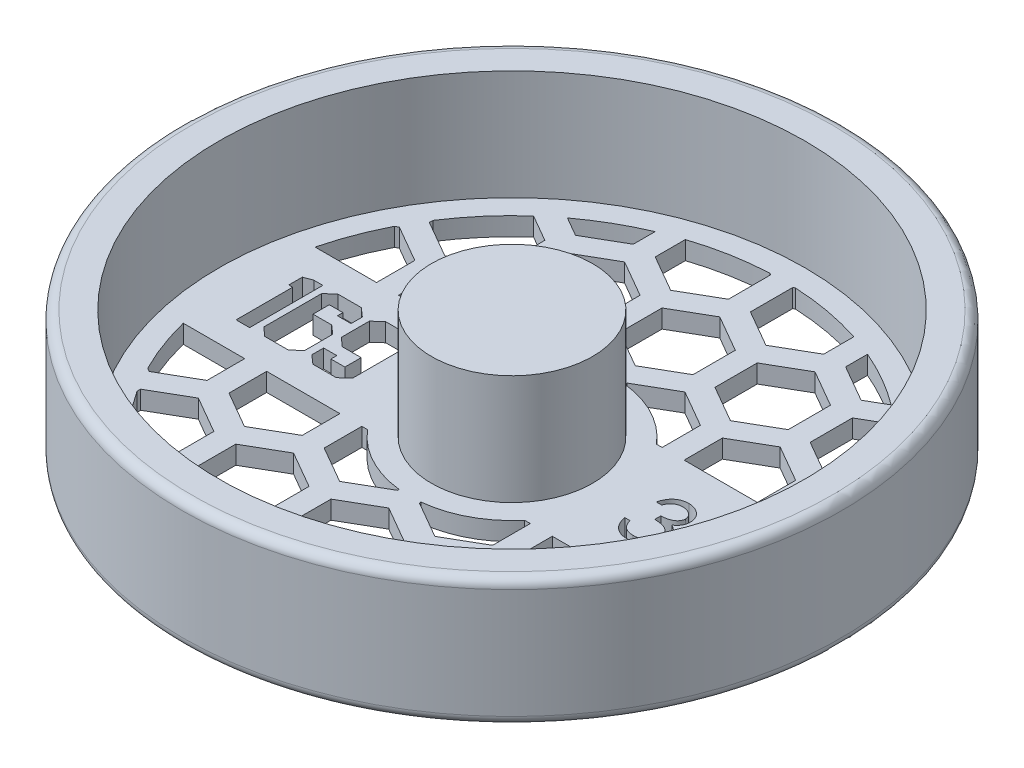
from build123d import *

# Parameters (mm, degrees)
CUT_EXTRUDE2_DEPTH      = 20.05
CUT_EXTRUDE2_DEPTH_BACK = 4.175
CUT_EXTRUDE4_DEPTH      = 20.05
CUT_EXTRUDE4_DEPTH_BACK = 4.1750001


with BuildPart() as part:
    # Sketch1 → Revolve1 (revolve)
    with BuildSketch(Plane.XY):
        with BuildLine():
            Line((0, 0), (0, 22.225))
            Line((0, 22.225), (13.97, 22.225))
            Line((13.97, 22.225), (13.97, 3.175))
            Line((13.97, 3.175), (50.8, 3.175))
            Line((50.8, 3.175), (50.8, 22.225))
            Line((50.8, 22.225), (55.5625, 22.225))
            ThreePointArc((55.5625, 22.225), (56.685032015, 21.760032015), (57.15, 20.6375))
            Line((57.15, 20.6375), (57.15, 1.5875))
            ThreePointArc((57.15, 1.5875), (56.685032015, 0.464967985), (55.5625, 0))
            Line((55.5625, 0), (0, 0))
        make_face()
    revolve(axis=Axis((0, 0, 0), (0, 1, 0)))

    # Sketch3 → Cut-Extrude2 (cut, two sides)
    with BuildSketch(Plane(origin=(0, 3.175, 0), x_dir=(1, 0, 0), z_dir=(0, 1, 0))) as cut_extrude2_sk:
        Polygon((-22.636037344, -5.022991324), (-24.137904564, -6.35), (-28.181208978, -6.35), (-29.68547152, -5.022991324), (-29.68547152, -2.979781215), (-27.397938514, -2.979781215), (-27.397938514, -4.004979253), (-24.978662769, -4.004979253), (-24.978662769, -1.176103357), (-28.253068653, -1.176103357), (-29.750145228, 0.150905319), (-29.750145228, 5.015805356), (-28.253068653, 6.35), (-24.154671822, 6.35), (-22.636037344, 5.008619389), align=None)
        Polygon((-30.945411166, -5.022991324), (-32.449673708, -6.35), (-36.524117314, -6.35), (-38.028379857, -5.022991324), (-38.028379857, 5.015805356), (-36.540884572, 6.35), (-32.473626933, 6.35), (-30.969364391, 5.015805356), (-30.969364391, 3.05164089), (-33.321571105, 3.05164089), (-33.321571105, 4.004979253), (-35.68335911, 4.004979253), (-35.68335911, 1.176103357), (-32.449673708, 1.176103357), (-30.945411166, -0.141324029), align=None)
        Polygon((-39.151786118, -6.35), (-41.496806865, -6.35), (-41.496806865, 3.463636364), (-42.167497171, 3.463636364), (-42.167497171, 5.808657111), (-40.720722369, 6.35), (-39.151786118, 6.35), align=None)
        with BuildLine():
            Line((23.201923077, 2.735384615), (22.290128205, 2.735384615))
            add(Edge.make_bspline(
                [(22.290128205, 2.735384615), (22.314830215, 2.837659483), (22.363120624, 3.037598484), (22.463842723, 3.323260704), (22.573568561, 3.593584984), (22.705326647, 3.843509586), (22.849043488, 4.078057258), (23.013701446, 4.291908202), (23.19170384, 4.490501268), (23.388589979, 4.666743123), (23.595066322, 4.826335617), (23.814042247, 4.962407212), (24.041112133, 5.079462467), (24.277849227, 5.175896054), (24.524958343, 5.248541575), (24.780205478, 5.301248187), (25.044259524, 5.335476107), (25.223503958, 5.338816608), (25.314519231, 5.340512821)],
                knots=[0, 0, 0, 0, 0.000315438, 0.000616656, 0.000907698, 0.001189895, 0.001463234, 0.001731895, 0.001998452, 0.002262133, 0.002523472, 0.002780414, 0.003034373, 0.003289106, 0.00354604, 0.003805892, 0.004070452, 0.004343366, 0.004343366, 0.004343366, 0.004343366], degree=3))
            add(Edge.make_bspline(
                [(25.314519231, 5.340512821), (25.447129705, 5.336509112), (25.709458034, 5.328589028), (26.094850193, 5.256265978), (26.466493759, 5.141820451), (26.820320833, 4.983691003), (27.148977769, 4.788655831), (27.441400528, 4.556529623), (27.693625462, 4.29179108), (27.905227427, 3.999378836), (28.070907996, 3.686870271), (28.193078726, 3.365233244), (28.267454805, 3.035230721), (28.277093907, 2.812415305), (28.281923077, 2.700785256)],
                knots=[0, 0, 0, 0, 0.000397506, 0.000786341, 0.001171951, 0.001561898, 0.001946195, 0.002315542, 0.002678309, 0.003039829, 0.003394922, 0.003736275, 0.004069616, 0.004404291, 0.004404291, 0.004404291, 0.004404291], degree=3))
            add(Edge.make_bspline(
                [(28.281923077, 2.700785256), (28.278545338, 2.593359818), (28.271935628, 2.383144906), (28.215812643, 2.076250503), (28.12136452, 1.787005171), (27.990533437, 1.514191284), (27.821176252, 1.259538606), (27.616023509, 1.022474191), (27.37362721, 0.801946578), (27.189937493, 0.675615765), (27.09536859, 0.610576923)],
                knots=[0, 0, 0, 0, 0.000322092, 0.000630284, 0.00093214, 0.001232539, 0.001535102, 0.001846808, 0.002171002, 0.002515015, 0.002515015, 0.002515015, 0.002515015], degree=3))
            add(Edge.make_bspline(
                [(27.09536859, 0.610576923), (27.203447054, 0.558388859), (27.417581752, 0.454989211), (27.709465575, 0.252207926), (27.974432208, 0.018074072), (28.122198432, -0.164639457), (28.196442308, -0.256442308)],
                knots=[0, 0, 0, 0, 0.000359556, 0.000712384, 0.001062596, 0.001416244, 0.001416244, 0.001416244, 0.001416244], degree=3))
            add(Edge.make_bspline(
                [(28.196442308, -0.256442308), (28.245330319, -0.323375667), (28.342305765, -0.456146304), (28.462006629, -0.669612044), (28.570599944, -0.885443795), (28.655218866, -1.109426528), (28.720747577, -1.338964191), (28.767588173, -1.574450918), (28.796686822, -1.816079006), (28.800854025, -1.979546091), (28.802948718, -2.061714744)],
                knots=[0, 0, 0, 0, 0.000248435, 0.000492801, 0.000733099, 0.000972742, 0.001209812, 0.001448502, 0.001692367, 0.001938844, 0.001938844, 0.001938844, 0.001938844], degree=3))
            add(Edge.make_bspline(
                [(28.802948718, -2.061714744), (28.797739502, -2.203982963), (28.787345583, -2.487849885), (28.694442328, -2.907239362), (28.550422178, -3.31719682), (28.345895758, -3.709299782), (28.096634646, -4.076163974), (27.800086528, -4.404408345), (27.45962084, -4.686562008), (27.079910728, -4.922303699), (26.668526149, -5.110751153), (26.228523859, -5.241546473), (25.766243702, -5.326733718), (25.449230519, -5.335868628), (25.288060897, -5.340512821)],
                knots=[0, 0, 0, 0, 0.000426322, 0.000850637, 0.001282577, 0.001726786, 0.002173324, 0.002609918, 0.00304927, 0.003495414, 0.003947167, 0.00440236, 0.004869477, 0.005352558, 0.005352558, 0.005352558, 0.005352558], degree=3))
            add(Edge.make_bspline(
                [(25.288060897, -5.340512821), (25.179438014, -5.337992521), (24.965704402, -5.333033413), (24.651488989, -5.299132102), (24.351560856, -5.237214144), (24.065514481, -5.153892549), (23.793095747, -5.048252521), (23.535135944, -4.916698815), (23.290048025, -4.76194314), (23.060144784, -4.582158782), (22.845453627, -4.38104495), (22.651680005, -4.155031367), (22.475593292, -3.908296046), (22.321908375, -3.637973117), (22.183625107, -3.347556028), (22.069888387, -3.033326101), (21.969781707, -2.698092483), (21.923238851, -2.4644771), (21.899358974, -2.344615385)],
                knots=[0, 0, 0, 0, 0.00032587, 0.000641203, 0.000946553, 0.001243456, 0.001534099, 0.001821726, 0.002110819, 0.002402315, 0.002696028, 0.002991841, 0.003293972, 0.003603973, 0.003923534, 0.004257744, 0.004605529, 0.004971988, 0.004971988, 0.004971988, 0.004971988], degree=3))
            Line((21.899358974, -2.344615385), (22.811153846, -2.344615385))
            add(Edge.make_bspline(
                [(22.811153846, -2.344615385), (22.834908772, -2.42284452), (22.881114167, -2.575006984), (22.959765043, -2.793999414), (23.049371227, -2.994755363), (23.14549806, -3.178747512), (23.246454921, -3.347787857), (23.359419389, -3.49740654), (23.476024679, -3.634175241), (23.563921316, -3.711230457), (23.606939103, -3.748942308)],
                knots=[0, 0, 0, 0, 0.000245255, 0.000477042, 0.000697536, 0.000904182, 0.001099652, 0.001287304, 0.001466129, 0.001637538, 0.001637538, 0.001637538, 0.001637538], degree=3))
            add(Edge.make_bspline(
                [(23.606939103, -3.748942308), (23.663825165, -3.792799643), (23.777421695, -3.880378935), (23.96253176, -3.992143662), (24.157211543, -4.088985953), (24.365679283, -4.162961481), (24.583436446, -4.225598348), (24.81400274, -4.266588198), (25.05534401, -4.294711575), (25.220132718, -4.297193319), (25.304342949, -4.298461538)],
                knots=[0, 0, 0, 0, 0.000215334, 0.000430002, 0.000647547, 0.000866467, 0.001092637, 0.001326558, 0.001568172, 0.001820675, 0.001820675, 0.001820675, 0.001820675], degree=3))
            add(Edge.make_bspline(
                [(25.304342949, -4.298461538), (25.399421688, -4.296673654), (25.585339954, -4.293177599), (25.85662606, -4.261026404), (26.114711679, -4.214202118), (26.356731373, -4.141883288), (26.58585536, -4.052530874), (26.798871805, -3.940340074), (26.998577074, -3.808710825), (27.182413291, -3.65910001), (27.347717964, -3.49531647), (27.493265808, -3.324009955), (27.616999111, -3.145902747), (27.716809727, -2.96000923), (27.795623895, -2.767099194), (27.849277986, -2.566631278), (27.886584099, -2.360246071), (27.889622264, -2.219953979), (27.891153846, -2.149230769)],
                knots=[0, 0, 0, 0, 0.000285118, 0.000557523, 0.000818576, 0.001071029, 0.001314045, 0.001555289, 0.001791808, 0.002030524, 0.002265109, 0.002488959, 0.002704052, 0.002914404, 0.003120759, 0.003327646, 0.003536098, 0.003748009, 0.003748009, 0.003748009, 0.003748009], degree=3))
            add(Edge.make_bspline(
                [(27.891153846, -2.149230769), (27.886711599, -2.054564711), (27.87784921, -1.86570364), (27.810187734, -1.587849196), (27.698895488, -1.320137805), (27.543091855, -1.067136997), (27.353431568, -0.832656094), (27.131755153, -0.623442877), (26.876221782, -0.450809698), (26.641032676, -0.331535198), (26.432708679, -0.250147574), (26.254428591, -0.19593682), (26.054837994, -0.150032037), (25.836350536, -0.107324414), (25.597319942, -0.07097673), (25.338006442, -0.04066563), (25.058357488, -0.01641214), (24.864762561, -0.005581303), (24.765, 0)],
                knots=[0, 0, 0, 0, 0.000283785, 0.000566158, 0.00085266, 0.001150399, 0.001454273, 0.001755223, 0.002061196, 0.002376128, 0.002544317, 0.00273166, 0.002934554, 0.003158479, 0.003399405, 0.003659679, 0.003941605, 0.004241348, 0.004241348, 0.004241348, 0.004241348], degree=3))
            Line((24.765, 0), (24.765, 1.042051282))
            add(Edge.make_bspline(
                [(24.765, 1.042051282), (24.890697098, 1.044184312), (25.136906836, 1.048362395), (25.496554303, 1.098895362), (25.840465404, 1.168797985), (26.16101846, 1.275870429), (26.453187297, 1.400229691), (26.706663627, 1.544943533), (26.917896261, 1.705804634), (27.085858685, 1.885295865), (27.212217818, 2.077798975), (27.304606464, 2.278434758), (27.359181125, 2.488961746), (27.36646633, 2.632637697), (27.370128205, 2.704855769)],
                knots=[0, 0, 0, 0, 0.000376792, 0.000738043, 0.001087728, 0.0014282, 0.001749964, 0.002039013, 0.002301593, 0.002543523, 0.002772704, 0.002989485, 0.00320372, 0.003420233, 0.003420233, 0.003420233, 0.003420233], degree=3))
            add(Edge.make_bspline(
                [(27.370128205, 2.704855769), (27.368925229, 2.757913452), (27.366531966, 2.863469196), (27.336350154, 3.017683681), (27.290995795, 3.16718357), (27.228643209, 3.311333099), (27.14518549, 3.449132523), (27.045309826, 3.58175666), (26.926385283, 3.708448316), (26.790109357, 3.826537472), (26.643771089, 3.939079029), (26.483388885, 4.034622616), (26.313798529, 4.11632371), (26.134812262, 4.183697579), (25.945849237, 4.234379399), (25.747797287, 4.270769155), (25.540278754, 4.293520747), (25.398701383, 4.296796377), (25.326730769, 4.298461538)],
                knots=[0, 0, 0, 0, 0.000158959, 0.000316241, 0.000469467, 0.000627144, 0.000785959, 0.000951629, 0.001124422, 0.00130612, 0.001492143, 0.001677485, 0.001865005, 0.002056287, 0.00225032, 0.00245111, 0.00265991, 0.002875801, 0.002875801, 0.002875801, 0.002875801], degree=3))
            add(Edge.make_bspline(
                [(25.326730769, 4.298461538), (25.21104707, 4.294422613), (24.9850899, 4.286533653), (24.659346027, 4.217436906), (24.356521903, 4.107191955), (24.125051945, 3.975596675), (23.954124244, 3.845692559), (23.831980903, 3.732241974), (23.712033365, 3.606162692), (23.602172771, 3.459689237), (23.491068885, 3.302741069), (23.3899201, 3.127339753), (23.291630251, 2.938060711), (23.232404564, 2.804251669), (23.201923077, 2.735384615)],
                knots=[0, 0, 0, 0, 0.000346717, 0.000677219, 0.00099404, 0.001310351, 0.001471548, 0.001637205, 0.001809999, 0.001992787, 0.002185868, 0.002386576, 0.002599579, 0.002825456, 0.002825456, 0.002825456, 0.002825456], degree=3))
        make_face()
        Polygon((35.05525641, 5.340512821), (30.805641026, -6.512820513), (29.845, -6.512820513), (34.094615385, 5.340512821), align=None)
        Polygon((41.38286859, 5.340512821), (41.568076923, 5.340512821), (41.568076923, -1.693333333), (42.740384615, -1.693333333), (42.740384615, -2.735384615), (41.568076923, -2.735384615), (41.568076923, -5.08), (40.656282051, -5.08), (40.656282051, -2.735384615), (35.836794872, -2.735384615), align=None)
    extrude(amount=CUT_EXTRUDE2_DEPTH, mode=Mode.SUBTRACT)
    extrude(cut_extrude2_sk.sketch, amount=-CUT_EXTRUDE2_DEPTH_BACK, mode=Mode.SUBTRACT)

    # Sketch4 → Cut-Extrude4 (cut, two sides)
    with BuildSketch(Plane(origin=(0, 3.175, 0), x_dir=(1, 0, 0), z_dir=(0, 1, 0))) as cut_extrude4_sk:
        with BuildLine():
            Line((-45.57867045, 11.43), (-34.925, 11.43))
            Line((-34.925, 11.43), (-34.925, 18.070094793))
            Line((-34.925, 18.070094793), (-41.275, 21.736269002))
            Line((-41.275, 21.736269002), (-41.824450692, 21.419043498))
            ThreePointArc((-41.824450692, 21.419043498), (-43.986039192, 16.531438418), (-45.57867045, 11.43))
        make_face()
        Polygon((-31.115, 11.43), (-18.415, 11.43), (-18.415, 18.070094793), (-24.765, 21.736269002), (-31.115, 18.070094793), align=None)
        with BuildLine():
            ThreePointArc((-31.304627771, 35.043977801), (-35.647925291, 30.61511918), (-39.37, 25.652742543))
            Line((-39.37, 25.652742543), (-39.37, 25.035825791))
            Line((-39.37, 25.035825791), (-33.02, 21.369651581))
            Line((-33.02, 21.369651581), (-26.67, 25.035825791))
            Line((-26.67, 25.035825791), (-26.67, 32.368174209))
            Line((-26.67, 32.368174209), (-31.304627771, 35.043977801))
        make_face()
        with BuildLine():
            ThreePointArc((-18.415, 43.231329785), (-23.408586329, 40.744302498), (-28.072243454, 37.683010063))
            Line((-28.072243454, 37.683010063), (-24.765, 35.773572165))
            Line((-24.765, 35.773572165), (-18.415, 39.439746374))
            Line((-18.415, 39.439746374), (-18.415, 43.231329785))
        make_face()
        Polygon((-16.51, 36.034348419), (-22.86, 32.368174209), (-22.86, 25.035825791), (-16.51, 21.369651581), (-10.16, 25.035825791), (-10.16, 32.368174209), align=None)
        with BuildLine():
            Line((-1.905, 46.772094793), (-2.193684728, 46.938766998))
            ThreePointArc((-2.193684728, 46.938766998), (-8.476090298, 46.21921671), (-14.605, 44.662669815))
            Line((-14.605, 44.662669815), (-14.605, 39.439746374))
            Line((-14.605, 39.439746374), (-8.255, 35.773572165))
            Line((-8.255, 35.773572165), (-1.905, 39.439746374))
            Line((-1.905, 39.439746374), (-1.905, 46.772094793))
        make_face()
        Polygon((-6.35, 25.035825791), (0, 21.369651581), (6.35, 25.035825791), (6.35, 32.368174209), (0, 36.034348419), (-6.35, 32.368174209), align=None)
        with BuildLine():
            ThreePointArc((-13.619232724, 11.43), (-8.367122494, 15.688201336), (-1.905, 17.677651852))
            Line((-1.905, 17.677651852), (-1.905, 18.070094793))
            Line((-1.905, 18.070094793), (-8.255, 21.736269002))
            Line((-8.255, 21.736269002), (-14.605, 18.070094793))
            Line((-14.605, 18.070094793), (-14.605, 11.43))
            Line((-14.605, 11.43), (-13.619232724, 11.43))
        make_face()
        with BuildLine():
            ThreePointArc((1.905, 17.677651852), (8.367122494, 15.688201336), (13.619232724, 11.43))
            Line((13.619232724, 11.43), (14.605, 11.43))
            Line((14.605, 11.43), (14.605, 18.070094793))
            Line((14.605, 18.070094793), (8.255, 21.736269002))
            Line((8.255, 21.736269002), (1.905, 18.070094793))
            Line((1.905, 18.070094793), (1.905, 17.677651852))
        make_face()
        with BuildLine():
            Line((14.605, 39.439746374), (14.605, 44.662669815))
            ThreePointArc((14.605, 44.662669815), (8.476090298, 46.21921671), (2.193684728, 46.938766998))
            Line((2.193684728, 46.938766998), (1.905, 46.772094793))
            Line((1.905, 46.772094793), (1.905, 39.439746374))
            Line((1.905, 39.439746374), (8.255, 35.773572165))
            Line((8.255, 35.773572165), (14.605, 39.439746374))
        make_face()
        Polygon((16.51, 36.034348419), (10.16, 32.368174209), (10.16, 25.035825791), (16.51, 21.369651581), (22.86, 25.035825791), (22.86, 32.368174209), align=None)
        with BuildLine():
            Line((24.765, 35.773572165), (28.072243454, 37.683010063))
            ThreePointArc((28.072243454, 37.683010063), (23.408586329, 40.744302498), (18.415, 43.231329785))
            Line((18.415, 43.231329785), (18.415, 39.439746374))
            Line((18.415, 39.439746374), (24.765, 35.773572165))
        make_face()
        with BuildLine():
            Line((39.37, 25.035825791), (39.37, 25.652742543))
            ThreePointArc((39.37, 25.652742543), (35.647925291, 30.61511918), (31.304627771, 35.043977801))
            Line((31.304627771, 35.043977801), (26.67, 32.368174209))
            Line((26.67, 32.368174209), (26.67, 25.035825791))
            Line((26.67, 25.035825791), (33.02, 21.369651581))
            Line((33.02, 21.369651581), (39.37, 25.035825791))
        make_face()
        Polygon((18.415, 18.070094793), (18.415, 11.43), (31.115, 11.43), (31.115, 18.070094793), (24.765, 21.736269002), align=None)
        with BuildLine():
            Line((34.925, 18.070094793), (34.925, 11.43))
            Line((34.925, 11.43), (45.57867045, 11.43))
            ThreePointArc((45.57867045, 11.43), (43.986039192, 16.531438418), (41.824450692, 21.419043498))
            Line((41.824450692, 21.419043498), (41.275, 21.736269002))
            Line((41.275, 21.736269002), (34.925, 18.070094793))
        make_face()
        with BuildLine():
            Line((45.57867045, -11.43), (34.925, -11.43))
            Line((34.925, -11.43), (34.925, -17.964253626))
            Line((34.925, -17.964253626), (41.275, -21.630427835))
            Line((41.275, -21.630427835), (41.900926719, -21.269048875))
            ThreePointArc((41.900926719, -21.269048875), (44.01558475, -16.452610707), (45.57867045, -11.43))
        make_face()
        Polygon((31.115, -11.43), (18.415, -11.43), (18.415, -17.964253626), (24.765, -21.630427835), (31.115, -17.964253626), align=None)
        with BuildLine():
            Line((14.605, -11.43), (13.619232724, -11.43))
            ThreePointArc((13.619232724, -11.43), (8.367122494, -15.688201336), (1.905, -17.677651852))
            Line((1.905, -17.677651852), (1.905, -17.964253626))
            Line((1.905, -17.964253626), (8.255, -21.630427835))
            Line((8.255, -21.630427835), (14.605, -17.964253626))
            Line((14.605, -17.964253626), (14.605, -11.43))
        make_face()
        with BuildLine():
            ThreePointArc((31.304627771, -35.043977801), (35.647925291, -30.61511918), (39.37, -25.652742543))
            Line((39.37, -25.652742543), (39.37, -25.035825791))
            Line((39.37, -25.035825791), (33.02, -21.369651581))
            Line((33.02, -21.369651581), (26.67, -25.035825791))
            Line((26.67, -25.035825791), (26.67, -32.368174209))
            Line((26.67, -32.368174209), (31.304627771, -35.043977801))
        make_face()
        with BuildLine():
            ThreePointArc((18.415, -43.231329785), (23.451826011, -40.719429721), (28.152186338, -37.623323942))
            Line((28.152186338, -37.623323942), (24.765, -35.667730998))
            Line((24.765, -35.667730998), (18.415, -39.333905207))
            Line((18.415, -39.333905207), (18.415, -43.231329785))
        make_face()
        Polygon((16.51, -21.369651581), (10.16, -25.035825791), (10.16, -32.368174209), (16.51, -36.034348419), (22.86, -32.368174209), (22.86, -25.035825791), align=None)
        with BuildLine():
            ThreePointArc((2.362789552, -46.930558547), (8.559339951, -46.203872128), (14.605, -44.662669815))
            Line((14.605, -44.662669815), (14.605, -39.333905207))
            Line((14.605, -39.333905207), (8.255, -35.667730998))
            Line((8.255, -35.667730998), (1.905, -39.333905207))
            Line((1.905, -39.333905207), (1.905, -46.666253626))
            Line((1.905, -46.666253626), (2.362789552, -46.930558547))
        make_face()
        Polygon((-6.35, -32.368174209), (0, -36.034348419), (6.35, -32.368174209), (6.35, -25.035825791), (0, -21.369651581), (-6.35, -25.035825791), align=None)
        with BuildLine():
            ThreePointArc((-14.605, -44.662669815), (-8.559339951, -46.203872128), (-2.362789552, -46.930558547))
            Line((-2.362789552, -46.930558547), (-1.905, -46.666253626))
            Line((-1.905, -46.666253626), (-1.905, -39.333905207))
            Line((-1.905, -39.333905207), (-8.255, -35.667730998))
            Line((-8.255, -35.667730998), (-14.605, -39.333905207))
            Line((-14.605, -39.333905207), (-14.605, -44.662669815))
        make_face()
        Polygon((-16.51, -21.369651581), (-22.86, -25.035825791), (-22.86, -32.368174209), (-16.51, -36.034348419), (-10.16, -32.368174209), (-10.16, -25.035825791), align=None)
        with BuildLine():
            Line((-24.765, -35.667730998), (-28.152186338, -37.623323942))
            ThreePointArc((-28.152186338, -37.623323942), (-23.451826011, -40.719429721), (-18.415, -43.231329785))
            Line((-18.415, -43.231329785), (-18.415, -39.333905207))
            Line((-18.415, -39.333905207), (-24.765, -35.667730998))
        make_face()
        with BuildLine():
            Line((-39.37, -25.035825791), (-39.37, -25.652742543))
            ThreePointArc((-39.37, -25.652742543), (-35.647925291, -30.61511918), (-31.304627771, -35.043977801))
            Line((-31.304627771, -35.043977801), (-26.67, -32.368174209))
            Line((-26.67, -32.368174209), (-26.67, -25.035825791))
            Line((-26.67, -25.035825791), (-33.02, -21.369651581))
            Line((-33.02, -21.369651581), (-39.37, -25.035825791))
        make_face()
        with BuildLine():
            Line((-34.925, -17.964253626), (-34.925, -11.43))
            Line((-34.925, -11.43), (-45.57867045, -11.43))
            ThreePointArc((-45.57867045, -11.43), (-44.01558475, -16.452610707), (-41.900926719, -21.269048875))
            Line((-41.900926719, -21.269048875), (-41.275, -21.630427835))
            Line((-41.275, -21.630427835), (-34.925, -17.964253626))
        make_face()
        Polygon((-18.415, -17.964253626), (-18.415, -11.43), (-31.115, -11.43), (-31.115, -17.964253626), (-24.765, -21.630427835), align=None)
        with BuildLine():
            Line((-1.905, -17.964253626), (-1.905, -17.677651852))
            ThreePointArc((-1.905, -17.677651852), (-8.367122494, -15.688201336), (-13.619232724, -11.43))
            Line((-13.619232724, -11.43), (-14.605, -11.43))
            Line((-14.605, -11.43), (-14.605, -17.964253626))
            Line((-14.605, -17.964253626), (-8.255, -21.630427835))
            Line((-8.255, -21.630427835), (-1.905, -17.964253626))
        make_face()
    extrude(amount=CUT_EXTRUDE4_DEPTH, mode=Mode.SUBTRACT)
    extrude(cut_extrude4_sk.sketch, amount=-CUT_EXTRUDE4_DEPTH_BACK, mode=Mode.SUBTRACT)


solid = part.part
